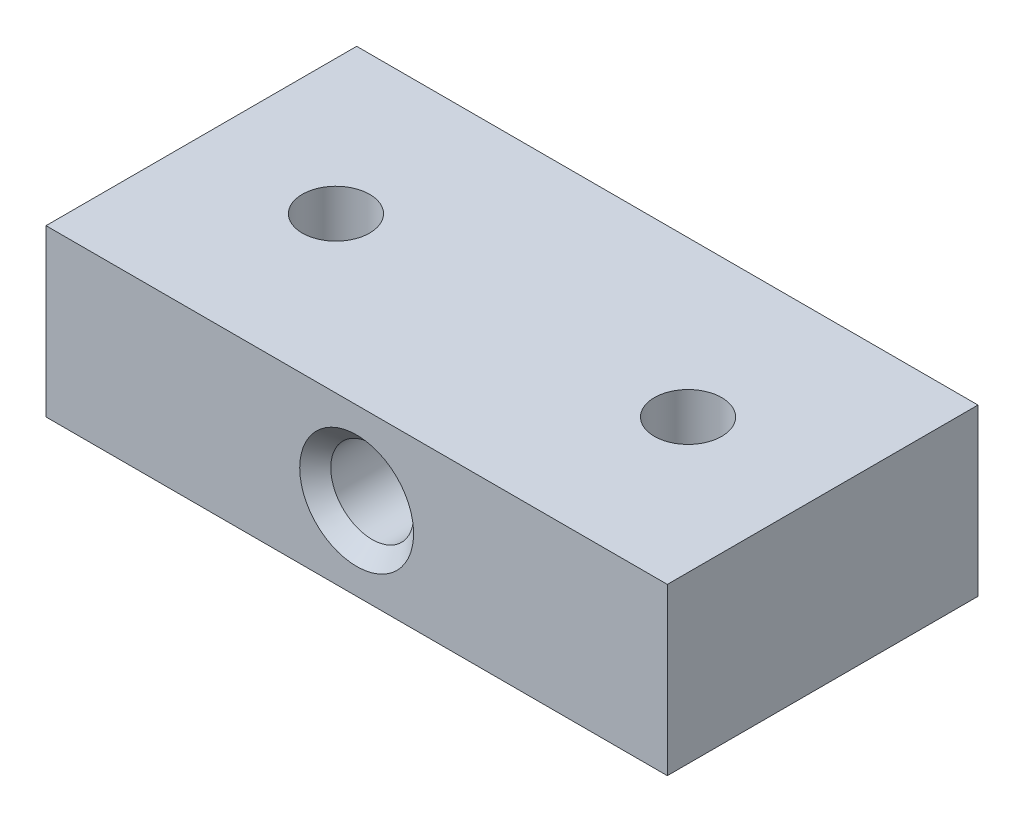
from build123d import *

# Parameters (mm, degrees)
SKETCH1_W           = 60
SKETCH1_H           = 30
SKETCH1_R           = 3.25
BOSS_EXTRUDE1_DEPTH = 16
SKETCH2_R           = 4
CUT_EXTRUDE1_DEPTH  = 31
CHAMFER1_SIZE       = 1.5


with BuildPart() as part:
    # Sketch1 → Boss-Extrude1 (new body)
    with BuildSketch(Plane(origin=(0, 0, 0), x_dir=(1, 0, 0), z_dir=(0, 1, 0))):
        with Locations((30, 15)):
            Rectangle(SKETCH1_W, SKETCH1_H)
        with Locations((13, 15)):
            Circle(SKETCH1_R, mode=Mode.SUBTRACT)
        with Locations((47, 15)):
            Circle(SKETCH1_R, mode=Mode.SUBTRACT)
    extrude(amount=BOSS_EXTRUDE1_DEPTH)

    # Sketch2 → Cut-Extrude1 (cut, through all)
    with BuildSketch(Plane.XY):
        with Locations((30, 8)):
            Circle(SKETCH2_R)
    extrude(amount=-CUT_EXTRUDE1_DEPTH, mode=Mode.SUBTRACT)

    # Chamfer1
    chamfer1_edges = [part.edges().sort_by_distance(p)[0] for p in [
        (26, 8, -30),
        (26, 8, 0),
    ]]
    chamfer(chamfer1_edges, length=CHAMFER1_SIZE)


solid = part.part
